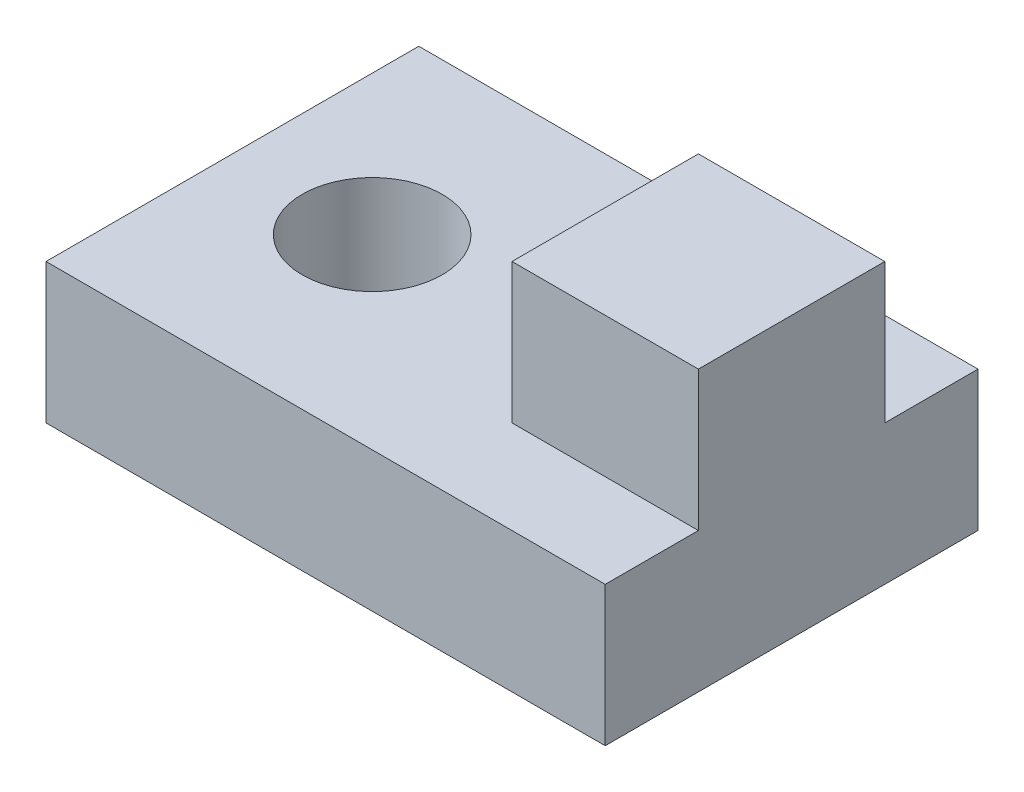
from build123d import *

# Parameters (mm, degrees)
SKETCH1_W           = 60
SKETCH1_H           = 40
BOSS_EXTRUDE1_DEPTH = 15
CUT_EXTRUDE1_REACH  = 17
SKETCH2_R           = 7.5
SKETCH3_W           = 20
SKETCH3_H           = 20
BOSS_EXTRUDE2_DEPTH = 15


with BuildPart() as part:
    # Sketch1 → Boss-Extrude1 (new body)
    with BuildSketch(Plane(origin=(0, 0, 0), x_dir=(1, 0, 0), z_dir=(0, 1, 0))):
        Rectangle(SKETCH1_W, SKETCH1_H)
    extrude(amount=BOSS_EXTRUDE1_DEPTH)

    # Sketch2 → Cut-Extrude1 (cut, up to next)
    with BuildSketch(Plane(origin=(0, 15, 0), x_dir=(1, 0, 0), z_dir=(0, 1, 0)), mode=Mode.PRIVATE) as cut_extrude1_sk1:
        with Locations((-15, 0)):
            Circle(SKETCH2_R)
    cut_extrude1_tool1 = extrude(cut_extrude1_sk1.sketch, amount=-CUT_EXTRUDE1_REACH, mode=Mode.PRIVATE) & part.part
    add(cut_extrude1_tool1.solids().sort_by_distance((-15, 15, 0))[0], mode=Mode.SUBTRACT)

    # Sketch3 → Boss-Extrude2 (add)
    with BuildSketch(Plane(origin=(0, 15, 0), x_dir=(1, 0, 0), z_dir=(0, 1, 0))):
        with Locations((20, 0)):
            Rectangle(SKETCH3_W, SKETCH3_H)
    extrude(amount=BOSS_EXTRUDE2_DEPTH)


solid = part.part
